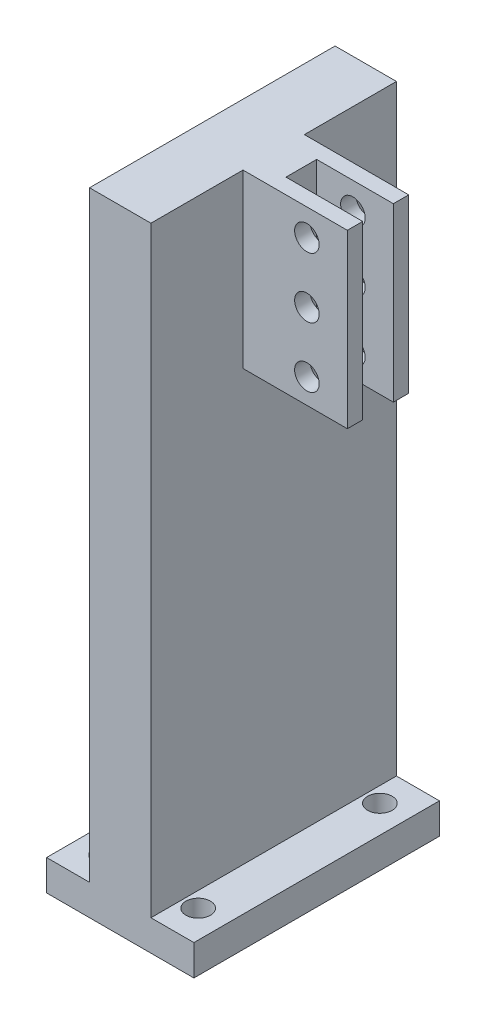
from build123d import *

# Parameters (mm, degrees)
SKETCH_1_W          = 24
SKETCH_1_H          = 40
SKETCH_1_R          = 2
EXTRUDE_1_DEPTH     = 5
EXTRUDE_5_DEPTH     = 98
SKETCH_10_W         = 10
SKETCH_10_H         = 28
EXTRUDE_6_DEPTH     = 18.5
SKETCH_12_R         = 2
CUT_EXTRUDE_4_DEPTH = 24.25
SKETCH_13_W         = 12
SKETCH_13_H         = 28
CUT_EXTRUDE_5_DEPTH = 2
SKETCH_14_W         = 2
SKETCH_14_H         = 4
CUT_EXTRUDE_6_DEPTH = 34
SKETCH_15_W         = 12.5
SKETCH_15_H         = 0.5
CUT_EXTRUDE_7_DEPTH = 34


with BuildPart() as part:
    # 草图1 → 凸台-拉伸1 (new body)
    with BuildSketch(Plane(origin=(0, 0, 0), x_dir=(1, 0, 0), z_dir=(0, 1, 0))):
        Rectangle(SKETCH_1_W, SKETCH_1_H)
        with Locations((7.5, -14.8)):
            Circle(SKETCH_1_R, mode=Mode.SUBTRACT)
        with Locations((-7.5, -14.8)):
            Circle(SKETCH_1_R, mode=Mode.SUBTRACT)
        with Locations((-7.5, 14.8)):
            Circle(SKETCH_1_R, mode=Mode.SUBTRACT)
        with Locations((7.5, 14.8)):
            Circle(SKETCH_1_R, mode=Mode.SUBTRACT)
    extrude(amount=EXTRUDE_1_DEPTH)

    # 草图8 → 凸台-拉伸5 (add)
    with BuildSketch(Plane(origin=(0, 5, 0), x_dir=(1, 0, 0), z_dir=(0, 1, 0))):
        Polygon((-5, 0), (-5, -20), (5, -20), (5, 20), (-5, 20), align=None)
    extrude(amount=EXTRUDE_5_DEPTH)

    # 草图10 → 凸台-拉伸6 (add)
    with BuildSketch(Plane(origin=(5, 0, 0), x_dir=(0, 0, -1), z_dir=(1, 0, 0))):
        with Locations((0, 89)):
            Rectangle(SKETCH_10_W, SKETCH_10_H)
    extrude(amount=EXTRUDE_6_DEPTH)

    # 草图12 → 切除-拉伸4 (cut, symmetric)
    with BuildSketch(Plane(origin=(0, 0, -5), x_dir=(-1, 0, 0), z_dir=(0, 0, -1))):
        with Locations((-15.41, 98.67)):
            Circle(SKETCH_12_R)
        with Locations((-15.41, 88.85)):
            Circle(SKETCH_12_R)
        with Locations((-15.41, 79.03)):
            Circle(SKETCH_12_R)
    extrude(amount=CUT_EXTRUDE_4_DEPTH, both=True, mode=Mode.SUBTRACT)

    # 草图13 → 切除-拉伸5 (cut, symmetric)
    with BuildSketch(Plane.XY):
        with Locations((17.5, 89)):
            Rectangle(SKETCH_13_W, SKETCH_13_H)
    extrude(amount=CUT_EXTRUDE_5_DEPTH, both=True, mode=Mode.SUBTRACT)

    # 草图14 → 切除-拉伸6 (cut)
    with BuildSketch(Plane(origin=(0, 103, 0), x_dir=(1, 0, 0), z_dir=(0, 1, 0))):
        with Locations((10.5, 0)):
            Rectangle(SKETCH_14_W, SKETCH_14_H)
        Polygon((22, 5), (23.5, 5), (23.5, 2), (23.5, -2), (23.5, -5), (22, -5), (22, -2.5), (22, 2.5), align=None)
    extrude(amount=-CUT_EXTRUDE_6_DEPTH, mode=Mode.SUBTRACT)

    # 草图15 → 切除-拉伸7 (cut)
    with BuildSketch(Plane(origin=(0, 103, 0), x_dir=(1, 0, 0), z_dir=(0, 1, 0))):
        with Locations((15.75, 2.25)):
            Rectangle(SKETCH_15_W, SKETCH_15_H)
        with Locations((15.75, -2.25)):
            Rectangle(SKETCH_15_W, SKETCH_15_H)
    extrude(amount=-CUT_EXTRUDE_7_DEPTH, mode=Mode.SUBTRACT)


solid = part.part
